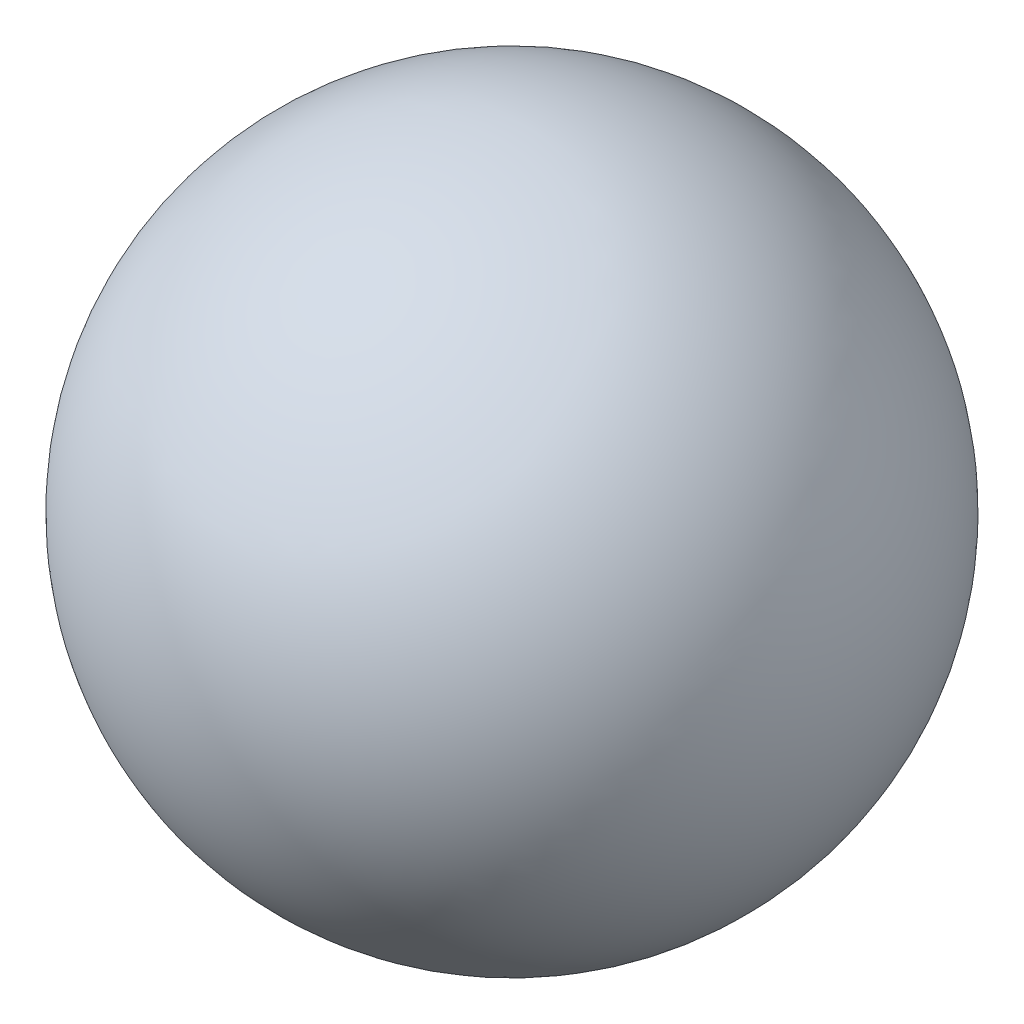
from build123d import *


with BuildPart() as part:
    # Эскиз1 → Повернуть1 (revolve)
    with BuildSketch(Plane(origin=(0, 0, 0), x_dir=(0, 0, -1), z_dir=(1, 0, 0))):
        with BuildLine():
            Line((-1.625, 0), (1.625, 0))
            ThreePointArc((1.625, 0), (0, 1.625), (-1.625, 0))
        make_face()
    revolve(axis=Axis((0, 0, 1.625), (0, 0, -1)))


solid = part.part
